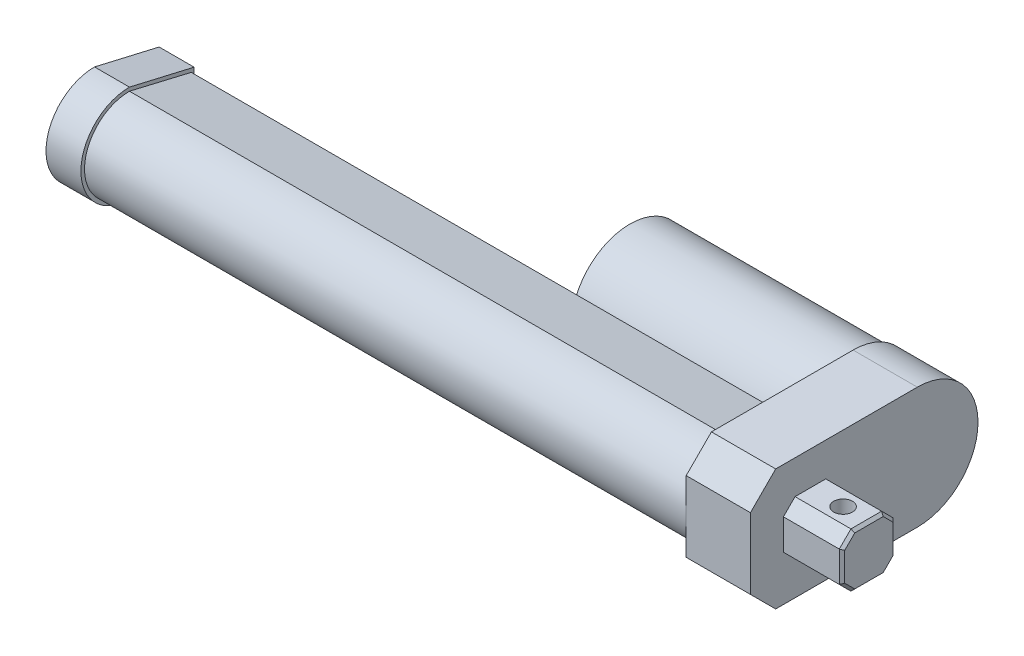
from build123d import *

# Parameters (mm, degrees)
SKETCH1_W           = 54.61
SKETCH1_H           = 39.6875
BOSS_EXTRUDE1_DEPTH = 21.0185
CHAMFER1_SIZE       = 8.261835623
SKETCH2_R           = 19.05
BOSS_EXTRUDE2_DEPTH = 73.025
SKETCH3_R           = 6.35
BOSS_EXTRUDE3_DEPTH = 2.54
BOSS_EXTRUDE4_DEPTH = 196.85
BOSS_EXTRUDE5_DEPTH = 11.43
SKETCH6_R           = 10.00125
CUT_EXTRUDE1_DEPTH  = 203.2
SKETCH7_W           = 17.653
SKETCH7_H           = 8.8265
BOSS_EXTRUDE6_DEPTH = 19.1643
CHAMFER2_SIZE       = 3.81
CUT_EXTRUDE2_DEPTH  = 17.653
CHAMFER3_SIZE       = 0.889


with BuildPart() as part:
    # Sketch1 → Boss-Extrude1 (new body)
    with BuildSketch(Plane(origin=(0, 0, 0), x_dir=(0, 0, -1), z_dir=(1, 0, 0))):
        with Locations((27.305, 19.84375)):
            Rectangle(SKETCH1_W, SKETCH1_H)
        with BuildLine():
            ThreePointArc((54.61, 39.6875), (74.45375, 19.84375), (54.61, 0))
            Line((54.61, 0), (54.61, 39.6875))
        make_face()
    extrude(amount=BOSS_EXTRUDE1_DEPTH)

    # Chamfer1
    chamfer1_edges = [part.edges().sort_by_distance(p)[0] for p in [
        (10.50925, 0, 0),
        (10.50925, 39.6875, 0),
    ]]
    chamfer(chamfer1_edges, length=CHAMFER1_SIZE)

    # Sketch2 → Boss-Extrude2 (add)
    with BuildSketch(Plane.ZY):
        with Locations((-54.61, 19.84375)):
            Circle(SKETCH2_R)
    extrude(amount=BOSS_EXTRUDE2_DEPTH)

    # Sketch3 → Boss-Extrude3 (add)
    with BuildSketch(Plane.ZY.offset(73.025)):
        with Locations((-54.61, 19.84375)):
            Circle(SKETCH3_R)
    extrude(amount=BOSS_EXTRUDE3_DEPTH)

    # Sketch4 → Boss-Extrude4 (add)
    with BuildSketch(Plane.ZY):
        with BuildLine():
            ThreePointArc((-14.7066, 5.13715), (-4.307463412, 9.444613412), (0, 19.84375))
            Line((0, 19.84375), (-14.7066, 19.84375))
            Line((-14.7066, 19.84375), (-34.925, 19.84375))
            Line((-34.925, 19.84375), (-34.925, 9.906))
            Line((-34.925, 9.906), (-14.7066, 5.13715))
        make_face()
        with BuildLine():
            Line((-14.7066, 19.84375), (0, 19.84375))
            ThreePointArc((0, 19.84375), (-4.307463412, 30.242886588), (-14.7066, 34.55035))
            Line((-14.7066, 34.55035), (-34.925, 29.7815))
            Line((-34.925, 29.7815), (-34.925, 19.84375))
            Line((-34.925, 19.84375), (-14.7066, 19.84375))
        make_face()
    extrude(amount=BOSS_EXTRUDE4_DEPTH)

    # Sketch5 → Boss-Extrude5 (add)
    with BuildSketch(Plane.ZY.offset(196.85)):
        with BuildLine():
            Line((-34.925, 19.84375), (0, 19.84375))
            ThreePointArc((0, 19.84375), (-4.307463412, 30.242886588), (-14.7066, 34.55035))
            Line((-14.7066, 34.55035), (-34.925, 29.7815))
            Line((-34.925, 29.7815), (-34.925, 19.84375))
        make_face()
        with BuildLine():
            Line((0, 19.84375), (1.168107566, 19.84375))
            ThreePointArc((1.168107566, 19.84375), (-3.481486631, 31.068863369), (-14.7066, 35.718457566))
            Line((-14.7066, 35.718457566), (-35.852392434, 30.7975))
            Line((-35.852392434, 30.7975), (-35.852392434, 19.84375))
            Line((-35.852392434, 19.84375), (-34.925, 19.84375))
            Line((-34.925, 19.84375), (-34.925, 29.7815))
            Line((-34.925, 29.7815), (-14.7066, 34.55035))
            ThreePointArc((-14.7066, 34.55035), (-4.307463412, 30.242886588), (0, 19.84375))
        make_face()
        with BuildLine():
            ThreePointArc((-14.7066, 5.13715), (-4.307463412, 9.444613412), (0, 19.84375))
            Line((0, 19.84375), (-34.925, 19.84375))
            Line((-34.925, 19.84375), (-34.925, 9.906))
            Line((-34.925, 9.906), (-14.7066, 5.13715))
        make_face()
        with BuildLine():
            ThreePointArc((-14.7066, 3.969042434), (-3.481486631, 8.618636631), (1.168107566, 19.84375))
            Line((1.168107566, 19.84375), (0, 19.84375))
            ThreePointArc((0, 19.84375), (-4.307463412, 9.444613412), (-14.7066, 5.13715))
            Line((-14.7066, 5.13715), (-34.925, 9.906))
            Line((-34.925, 9.906), (-34.925, 19.84375))
            Line((-34.925, 19.84375), (-35.852392434, 19.84375))
            Line((-35.852392434, 19.84375), (-35.852392434, 8.89))
            Line((-35.852392434, 8.89), (-14.7066, 3.969042434))
        make_face()
    extrude(amount=BOSS_EXTRUDE5_DEPTH)

    # Sketch6 → Cut-Extrude1 (cut)
    with BuildSketch(Plane.ZY.offset(208.28)):
        with Locations((-14.7066, 19.84375)):
            Circle(SKETCH6_R)
    extrude(amount=-CUT_EXTRUDE1_DEPTH, mode=Mode.SUBTRACT)

    # Sketch7 → Boss-Extrude6 (add)
    with BuildSketch(Plane(origin=(21.0185, 0, 0), x_dir=(0, 0, -1), z_dir=(1, 0, 0))):
        with Locations((19.6215, 15.4305)):
            Rectangle(SKETCH7_W, SKETCH7_H)
        with Locations((19.6215, 24.257)):
            Rectangle(SKETCH7_W, SKETCH7_H)
    extrude(amount=BOSS_EXTRUDE6_DEPTH)

    # Chamfer2
    chamfer2_edges = [part.edges().sort_by_distance(p)[0] for p in [
        (30.60065, 11.01725, -10.795),
        (30.60065, 11.01725, -28.448),
        (30.60065, 28.67025, -28.448),
        (30.60065, 28.67025, -10.795),
    ]]
    chamfer(chamfer2_edges, length=CHAMFER2_SIZE)

    # Sketch8 → Cut-Extrude2 (cut)
    with BuildSketch(Plane.XZ.offset(-11.01725)):
        with BuildLine():
            ThreePointArc((28.6385, -19.6215), (31.7119, -22.6949), (34.7853, -19.6215))
            Line((34.7853, -19.6215), (28.6385, -19.6215))
        make_face()
        with BuildLine():
            Line((28.6385, -19.6215), (34.7853, -19.6215))
            ThreePointArc((34.7853, -19.6215), (31.7119, -16.5481), (28.6385, -19.6215))
        make_face()
    extrude(amount=-CUT_EXTRUDE2_DEPTH, mode=Mode.SUBTRACT)

    # Chamfer3
    chamfer3_edges = [part.edges().sort_by_distance(p)[0] for p in [
        (40.1828, 19.84375, -10.795),
        (40.1828, 28.67025, -19.6215),
        (40.1828, 11.01725, -19.6215),
        (40.1828, 19.84375, -28.448),
        (40.1828, 12.92225, -12.7),
        (40.1828, 12.92225, -26.543),
        (40.1828, 26.76525, -26.543),
        (40.1828, 26.76525, -12.7),
    ]]
    chamfer(chamfer3_edges, length=CHAMFER3_SIZE)


solid = part.part
